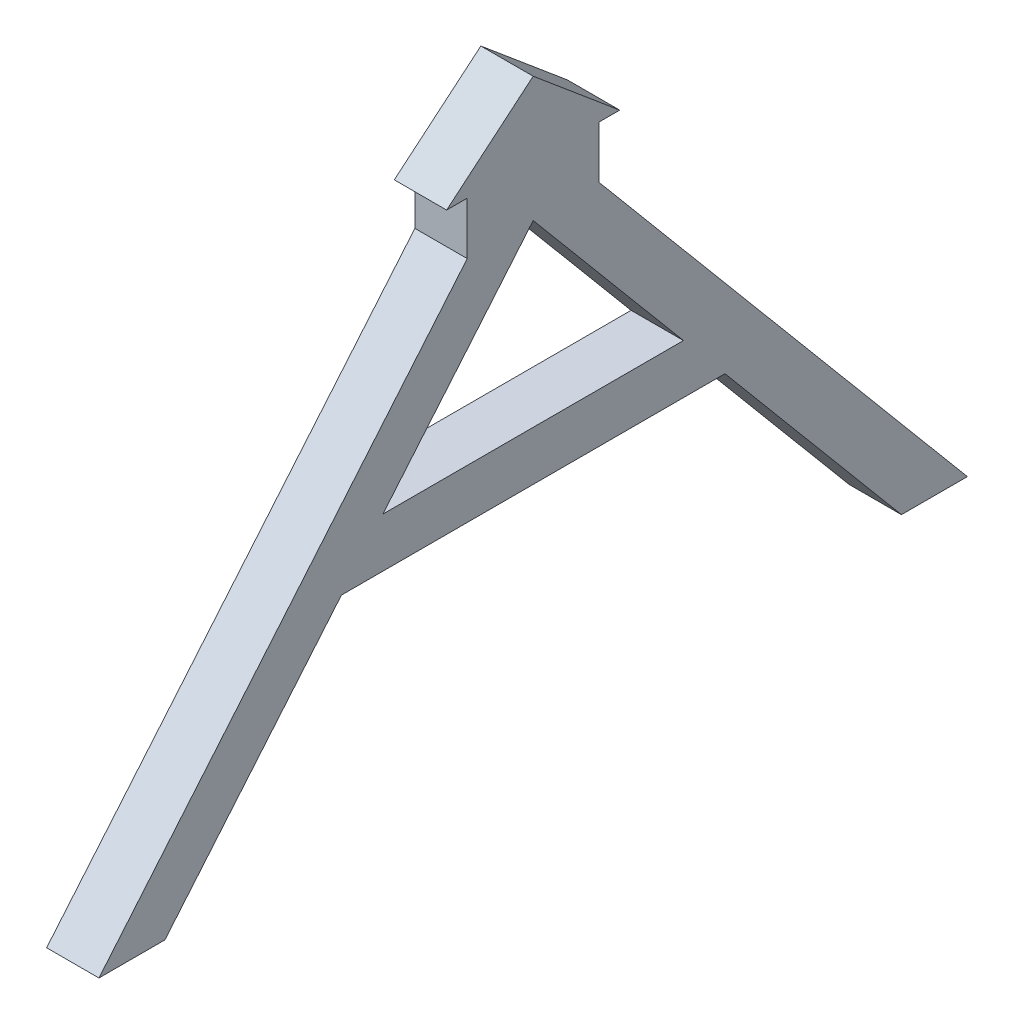
from build123d import *

# Parameters (mm, degrees)
BOSS_EXTRUDE2_DEPTH = 3.175


with BuildPart() as part:
    # Sketch1 → Boss-Extrude2 (new body)
    with BuildSketch(Plane(origin=(0, 0, 0), x_dir=(0, 0, -1), z_dir=(1, 0, 0))):
        Polygon((0, 0), (1.25, 0), (1.25, -3.175), (-21.087781289, -29.796131102), (-17.087781289, -29.796131102), (-6.381931526, -17.037396185), (16.881931526, -17.037396185), (27.587781289, -29.796131102), (31.587781289, -29.796131102), (9.25, -3.175), (9.25, 0), (10.5, 0), (5.25, 4.405273064), align=None)
        Polygon((5.25, -3.175), (14.364632633, -14.037396185), (-3.864632633, -14.037396185), align=None, mode=Mode.SUBTRACT)
    extrude(amount=BOSS_EXTRUDE2_DEPTH)


solid = part.part
